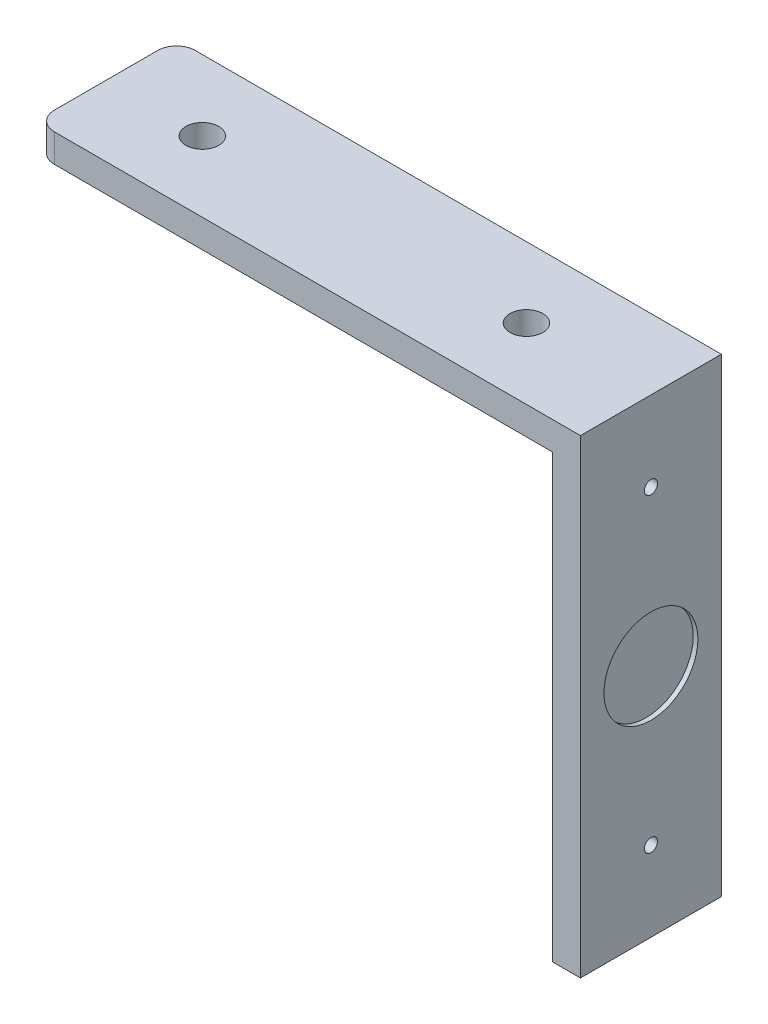
from build123d import *

# Parameters (mm, degrees)
SKETCH1_W           = 55
SKETCH1_H           = 15
BOSS_EXTRUDE1_DEPTH = 3
FILLET8_R           = 2
FILLET9_R           = 2
SKETCH2_R           = 1.75
CUT_EXTRUDE1_DEPTH  = 3
SKETCH4_W           = 3
SKETCH4_H           = 15
BOSS_EXTRUDE2_DEPTH = 50
SKETCH6_R           = 0.7
CUT_EXTRUDE2_DEPTH  = 50
SKETCH7_R           = 5
CUT_EXTRUDE3_DEPTH  = 0.5


with BuildPart() as part:
    # Sketch1 → Boss-Extrude1 (new body)
    with BuildSketch(Plane(origin=(0, 0, 0), x_dir=(1, 0, 0), z_dir=(0, 1, 0))):
        with Locations((13.774194124, -13.172794988)):
            Rectangle(SKETCH1_W, SKETCH1_H)
    extrude(amount=BOSS_EXTRUDE1_DEPTH)

    # Fillet8
    fillet8_edges = [part.edges().sort_by_distance(p)[0] for p in [
        (-13.725805876, 1.5, 5.672794988),
    ]]
    fillet(fillet8_edges, radius=FILLET8_R)

    # Fillet9
    fillet9_edges = [part.edges().sort_by_distance(p)[0] for p in [
        (-13.725805876, 1.5, 20.672794988),
    ]]
    fillet(fillet9_edges, radius=FILLET9_R)

    # Sketch2 → Cut-Extrude1 (cut)
    with BuildSketch(Plane(origin=(0, 3, 0), x_dir=(1, 0, 0), z_dir=(0, 1, 0))):
        with Locations((-3.475805876, -13.172794988)):
            Circle(SKETCH2_R)
    cut_extrude1 = extrude(amount=-CUT_EXTRUDE1_DEPTH, mode=Mode.SUBTRACT)

    # Mirror1: Cut-Extrude1 across plane
    add(cut_extrude1.mirror(Plane.ZY.offset(-13.774194124)), mode=Mode.SUBTRACT)

    # Sketch4 → Boss-Extrude2 (add)
    with BuildSketch(Plane(origin=(0, 3, 0), x_dir=(1, 0, 0), z_dir=(0, 1, 0))):
        with Locations((42.774194124, -13.172794988)):
            Rectangle(SKETCH4_W, SKETCH4_H)
    extrude(amount=-BOSS_EXTRUDE2_DEPTH)

    # Sketch6 → Cut-Extrude2 (cut)
    with BuildSketch(Plane(origin=(44.274194124, 0, 0), x_dir=(0, 0, -1), z_dir=(1, 0, 0))):
        with Locations((-13.172794988, -5.5)):
            Circle(SKETCH6_R)
    cut_extrude2 = extrude(amount=-CUT_EXTRUDE2_DEPTH, mode=Mode.SUBTRACT)

    # Mirror2: Cut-Extrude2 across plane
    add(cut_extrude2.mirror(Plane(origin=(0, -22, 0), x_dir=(0, 0, 1), z_dir=(0, -1, 0))), mode=Mode.SUBTRACT)

    # Sketch7 → Cut-Extrude3 (cut)
    with BuildSketch(Plane(origin=(44.274194124, 0, 0), x_dir=(0, 0, -1), z_dir=(1, 0, 0))):
        with Locations((-13.172794988, -22)):
            Circle(SKETCH7_R)
    extrude(amount=-CUT_EXTRUDE3_DEPTH, mode=Mode.SUBTRACT)


solid = part.part
